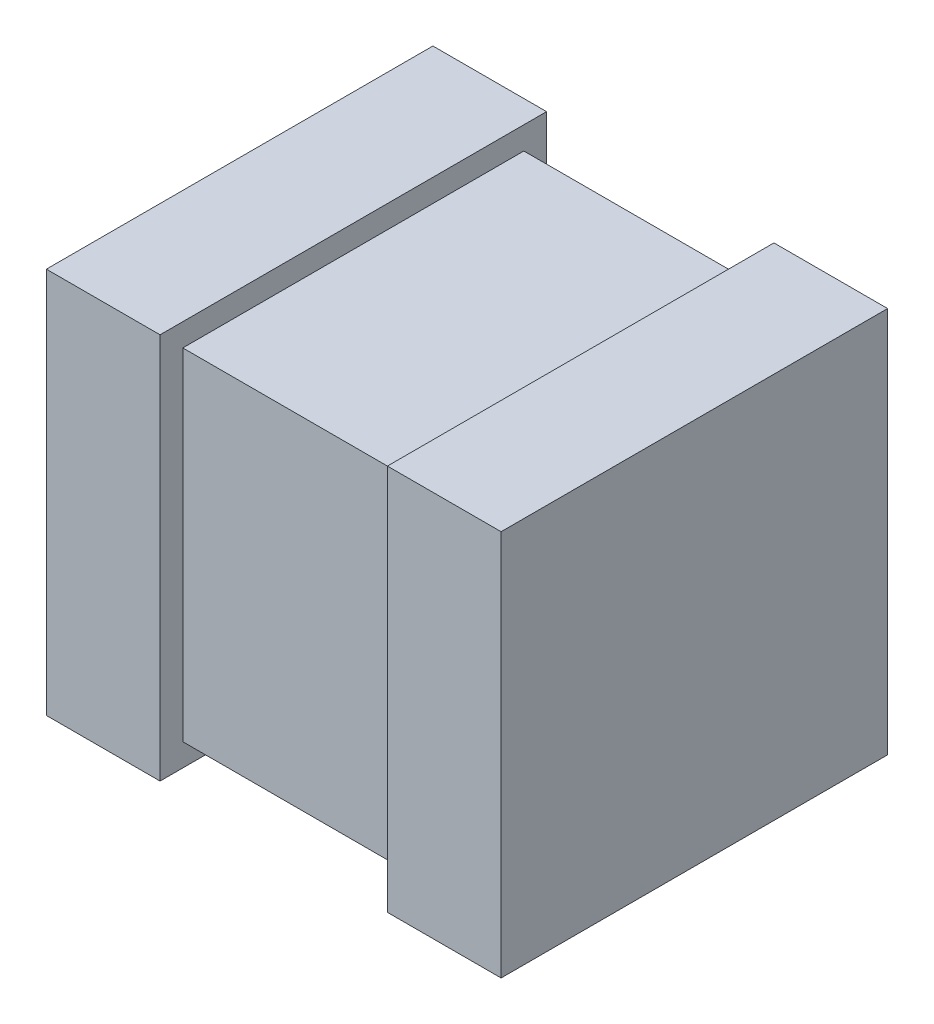
from build123d import *

# Parameters (mm, degrees)
CHIP_W              = 1.016
CHIP_H              = 0.762
CHIP_CAP_DEPTH      = 0.762
SOLDER_BAND_W       = 0.8636
SOLDER_BAND_H       = 0.8636
SOLDER_BAND_R_DEPTH = 0.254
SKETCH3_W           = 0.8636
SKETCH3_H           = 0.8636
SOLDER_BAND_L_DEPTH = 0.254


with BuildPart() as part:
    # Chip → Chip Cap (new body)
    with BuildSketch(Plane.XY):
        Rectangle(CHIP_W, CHIP_H)
    extrude(amount=CHIP_CAP_DEPTH)

    # Solder Band → Solder Band R (add)
    with BuildSketch(Plane(origin=(0.508, 0, 0), x_dir=(0, 0, -1), z_dir=(1, 0, 0))):
        with Locations((-0.381, 0)):
            Rectangle(SOLDER_BAND_W, SOLDER_BAND_H)
    extrude(amount=-SOLDER_BAND_R_DEPTH)

    # Sketch3 → Solder Band L (add)
    with BuildSketch(Plane.ZY.offset(0.508)):
        with Locations((0.381, 0)):
            Rectangle(SKETCH3_W, SKETCH3_H)
    extrude(amount=-SOLDER_BAND_L_DEPTH)


solid = part.part
